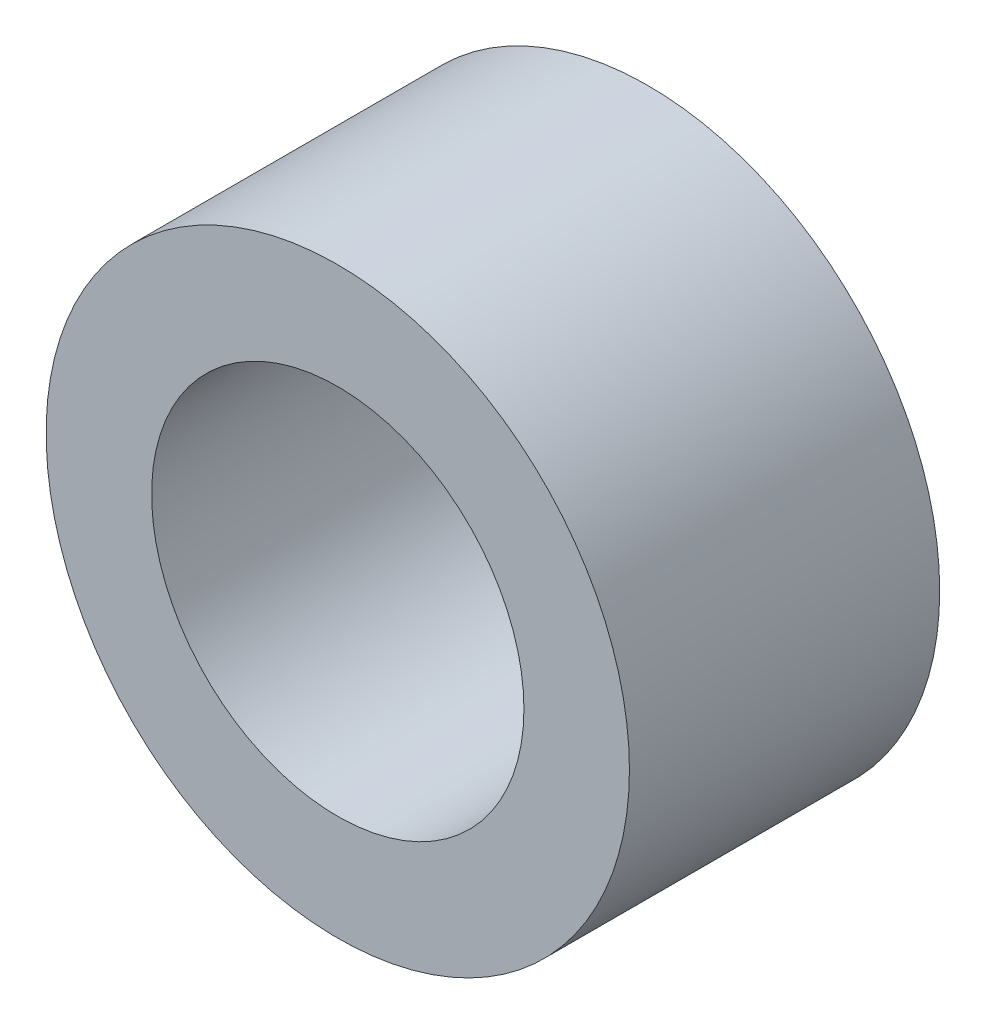
from build123d import *

# Parameters (mm, degrees)
SKETCH1_R      = 4.7
SKETCH1_R_2    = 3
EXTRUDE1_DEPTH = 5


with BuildPart() as part:
    # Sketch1 → Extrude1 (new body)
    with BuildSketch(Plane.XY):
        Circle(SKETCH1_R)
        Circle(SKETCH1_R_2, mode=Mode.SUBTRACT)
    extrude(amount=EXTRUDE1_DEPTH)


solid = part.part
